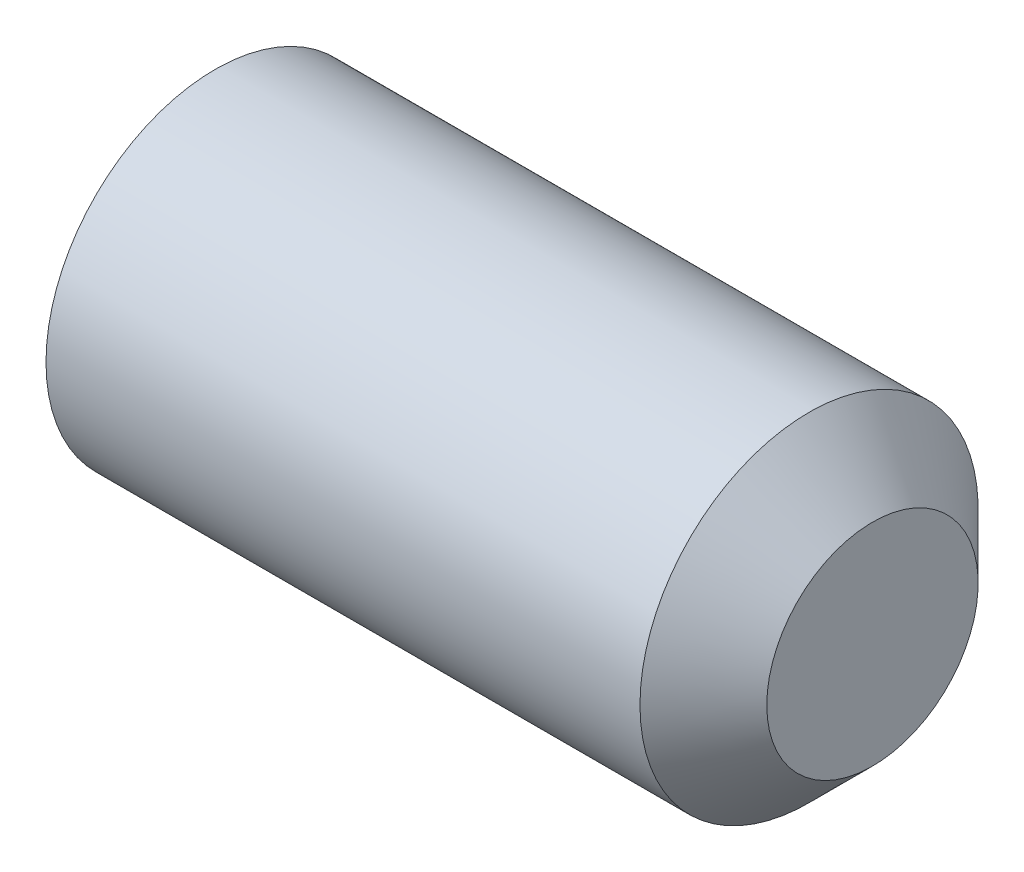
from build123d import *

# Parameters (mm, degrees)
HEX_2_DEPTH = 2.5


with BuildPart() as part:
    # BodySke → BaseBody (revolve)
    with BuildSketch(Plane.XY, mode=Mode.PRIVATE) as basebody_sk:
        Polygon((0, 0), (0, 1.61), (0.225166605, 2), (7.25, 2), (8, 1.25), (8, 0), align=None)
    revolve(basebody_sk.sketch.rotate(Axis((-12.7, 0, 0), (1, 0, 0)), 90), axis=Axis((-12.7, 0, 0), (1, 0, 0)))  # turned: the seam where the file's is

    # Sketch2 → Hex 2 (cut)
    with BuildSketch(Plane.ZY):
        Polygon((0.577350269, 1), (-0.577350269, 1), (-1.154700538, 0), (-0.577350269, -1), (0.577350269, -1), (1.154700538, 0), align=None)
    extrude(amount=-HEX_2_DEPTH, mode=Mode.SUBTRACT)


solid = part.part
